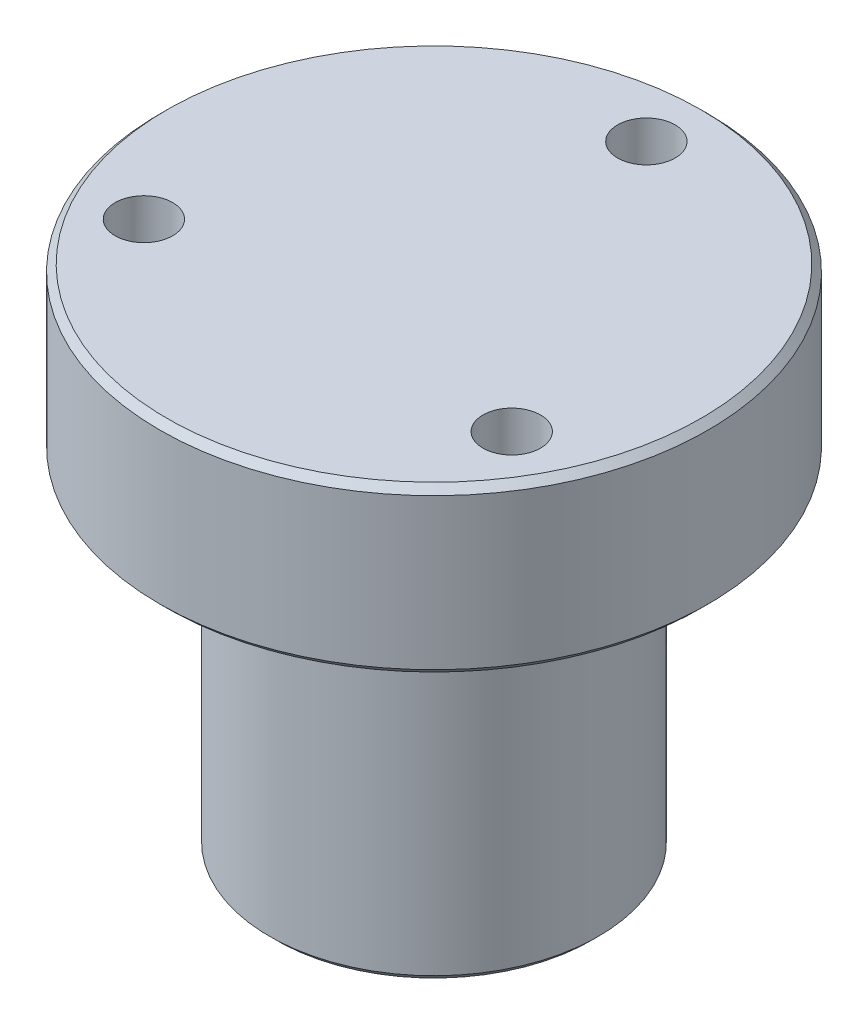
from build123d import *

# Parameters (mm, degrees)
SKETCH2_R          = 2.10058
CUT_EXTRUDE1_DEPTH = 38


with BuildPart() as part:
    # Sketch1 → Revolve1 (revolve)
    with BuildSketch(Plane.XY):
        Polygon((0, 0), (0, 37), (19.5, 37), (20, 36.5), (20, 25.5), (19.5, 25), (12, 25), (12, 0.5), (11.5, 0), align=None)
    revolve(axis=Axis((0, 0, 0), (0, 1, 0)))

    # Sketch2 → Cut-Extrude1 (cut, through all)
    with BuildSketch(Plane(origin=(0, 37, 0), x_dir=(1, 0, 0), z_dir=(0, 1, 0))):
        with Locations((0, 15.5)):
            Circle(SKETCH2_R)
        with Locations((13.423393759, -7.75)):
            Circle(SKETCH2_R)
        with Locations((-13.423393759, -7.75)):
            Circle(SKETCH2_R)
    extrude(amount=-CUT_EXTRUDE1_DEPTH, mode=Mode.SUBTRACT)


solid = part.part
